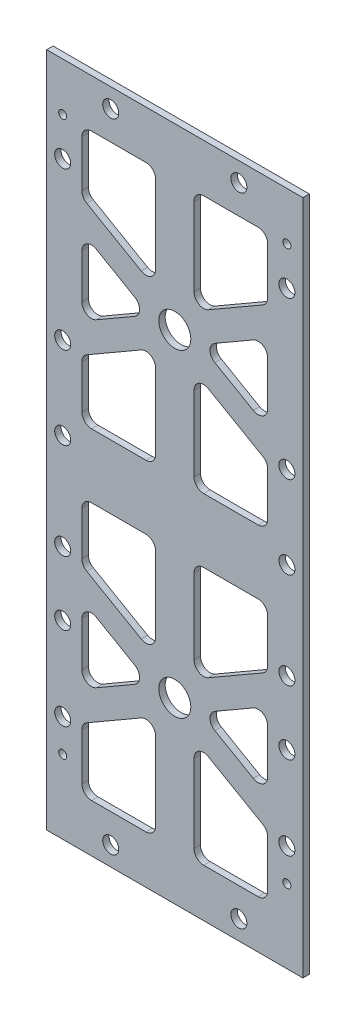
from build123d import *

# Parameters (mm, degrees)
SKETCH1_W                   = 88
SKETCH1_H                   = 211
BOSS_EXTRUDE1_DEPTH         = 2
CUT_EXTRUDE2_DEPTH          = 2
SKETCH4_R                   = 5
CUT_EXTRUDE3_DEPTH          = 3
FILLET2_R                   = 3
SKETCH23_W                  = 2
SKETCH23_H                  = 211
SKETCH23_W_2                = 2.150374681
CUT_EXTRUDE5_DEPTH          = 10
SKETCH29_W                  = 5.911493913
SKETCH29_H                  = 211
SKETCH29_W_2                = 4.036537762
CUT_EXTRUDE10_DEPTH         = 2
F_5_0MM_DOWEL_HOLE1_D       = 5
TAP_DRILL_FOR_M3X0_5_TAP1_D = 2.5


with BuildPart() as part:
    # Sketch1 → Boss-Extrude1 (new body)
    with BuildSketch(Plane.XY):
        with Locations((44, 105.5)):
            Rectangle(SKETCH1_W, SKETCH1_H)
    extrude(amount=BOSS_EXTRUDE1_DEPTH)

    # Sketch3 → Cut-Extrude2 (cut)
    with BuildSketch(Plane.XY.offset(2)):
        Polygon((73, 133.88804004), (50, 147.167096231), (50, 115.5), (73, 115.5), align=None)
        Polygon((38, 115.5), (38, 147.167096231), (15, 133.88804004), (15, 115.5), align=None)
        Polygon((15, 143.125644347), (36, 155.25), (15, 167.374355653), align=None)
        Polygon((73, 143.125644347), (73, 167.374355653), (52, 155.25), align=None)
        Polygon((73, 196), (50, 196), (50, 163.332903769), (73, 176.61195996), align=None)
        Polygon((38, 163.332903769), (38, 196), (15, 196), (15, 176.61195996), align=None)
    cut_extrude2 = extrude(amount=-CUT_EXTRUDE2_DEPTH, mode=Mode.SUBTRACT)

    # Sketch4 → Cut-Extrude3 (cut, through all)
    with BuildSketch(Plane.XY.offset(2)):
        with Locations((44, 155.25)):
            Circle(SKETCH4_R)
    cut_extrude3 = extrude(amount=-CUT_EXTRUDE3_DEPTH, mode=Mode.SUBTRACT)

    # Mirror2: Cut-Extrude2, Cut-Extrude3 across plane
    add(cut_extrude2.mirror(Plane.ZX.offset(105.5)), mode=Mode.SUBTRACT)
    add(cut_extrude3.mirror(Plane.ZX.offset(105.5)), mode=Mode.SUBTRACT)

    # Fillet2
    fillet2_edges = [part.edges().sort_by_distance(p)[0] for p in [
        (36, 55.75, 1),
        (15, 43.625644347, 1),
        (15, 67.874355653, 1),
        (38, 95.5, 1),
        (38, 63.832903769, 1),
        (15, 77.11195996, 1),
        (15, 95.5, 1),
        (73, 15, 1),
        (50, 15, 1),
        (50, 47.667096231, 1),
        (73, 34.38804004, 1),
        (73, 43.625644347, 1),
        (52, 55.75, 1),
        (73, 67.874355653, 1),
        (15, 15, 1),
        (15, 34.38804004, 1),
        (38, 47.667096231, 1),
        (38, 15, 1),
        (73, 77.11195996, 1),
        (50, 63.832903769, 1),
        (50, 95.5, 1),
        (73, 95.5, 1),
        (15, 167.374355653, 1),
        (36, 155.25, 1),
        (15, 143.125644347, 1),
        (38, 147.167096231, 1),
        (38, 115.5, 1),
        (15, 115.5, 1),
        (15, 133.88804004, 1),
        (50, 196, 1),
        (73, 196, 1),
        (73, 176.61195996, 1),
        (50, 163.332903769, 1),
        (52, 155.25, 1),
        (73, 167.374355653, 1),
        (73, 143.125644347, 1),
        (15, 176.61195996, 1),
        (15, 196, 1),
        (38, 196, 1),
        (38, 163.332903769, 1),
        (50, 147.167096231, 1),
        (73, 133.88804004, 1),
        (73, 115.5, 1),
        (50, 115.5, 1),
    ]]
    fillet(fillet2_edges, radius=FILLET2_R)

    # Sketch23 → Cut-Extrude5 (cut)
    with BuildSketch(Plane.XY.offset(2)):
        with Locations((87, 105.5)):
            Rectangle(SKETCH23_W, SKETCH23_H)
        with Locations((1.075187341, 105.5)):
            Rectangle(SKETCH23_W_2, SKETCH23_H)
    extrude(amount=-CUT_EXTRUDE5_DEPTH, mode=Mode.SUBTRACT)

    # Sketch29 → Cut-Extrude10 (cut)
    with BuildSketch(Plane(origin=(0, 0, 0), x_dir=(-1, 0, 0), z_dir=(0, 0, -1))):
        with Locations((-1.044253043, 105.5)):
            Rectangle(SKETCH29_W, SKETCH29_H)
        with Locations((-86.018268881, 105.5)):
            Rectangle(SKETCH29_W_2, SKETCH29_H)
    extrude(amount=-CUT_EXTRUDE10_DEPTH, mode=Mode.SUBTRACT)

    # Ø5.0mm Dowel Hole1 (through all)
    with Locations(Plane.XY.offset(2)):
        with Locations((24, 205), (64, 205), (9, 184), (79, 184), (9, 135), (79, 135), (79, 109.2), (9, 109.2), (9, 79.2), (79, 79.2), (79, 59.2), (9, 59.2), (9, 33.2), (79, 33.2), (64, 6), (24, 6)):
            Hole(F_5_0MM_DOWEL_HOLE1_D / 2)

    # Tap Drill for M3x0.5 Tap1 (through all)
    with Locations(Plane.XY.offset(2)):
        with Locations((9, 23), (79, 23), (9, 196), (79, 196)):
            Hole(TAP_DRILL_FOR_M3X0_5_TAP1_D / 2)


solid = part.part
